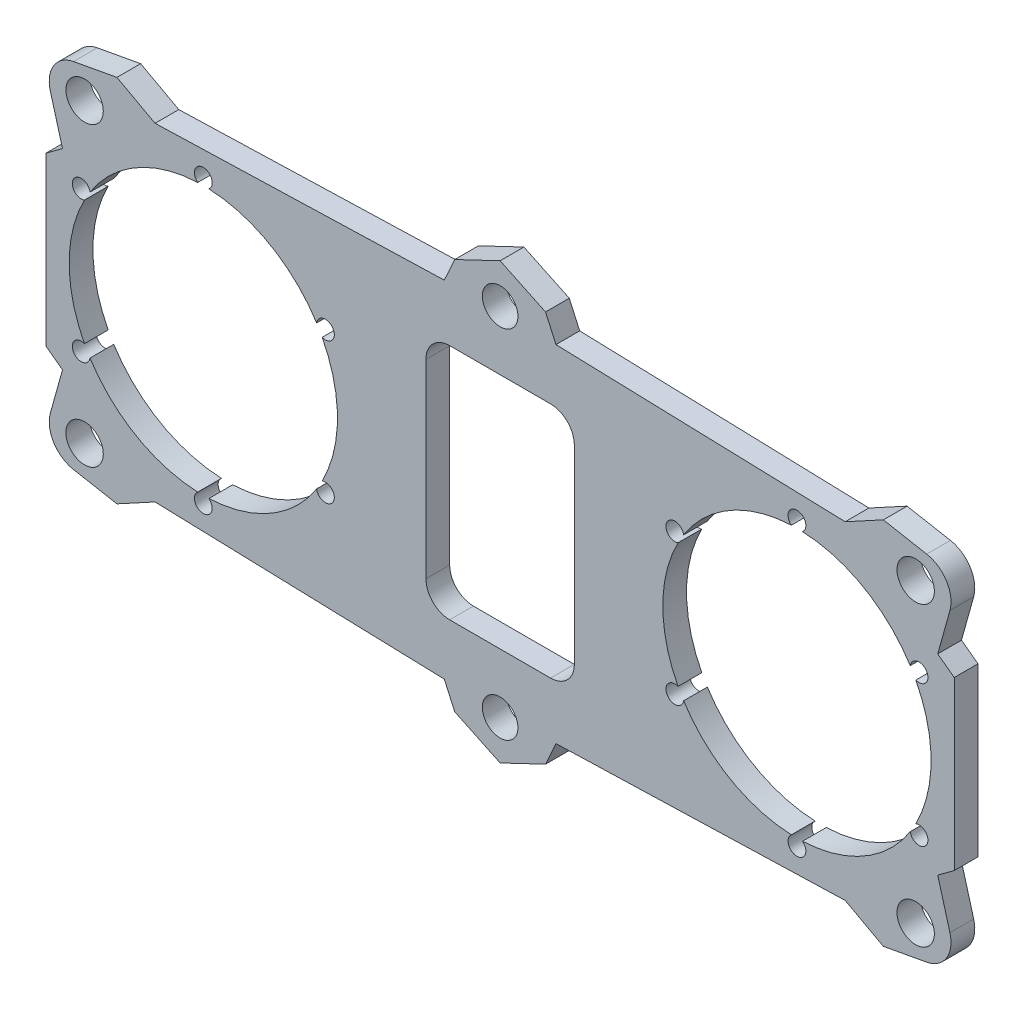
from build123d import *

# Parameters (mm, degrees)
SKETCH1_R           = 3
SKETCH1_R_2         = 22.6
BOSS_EXTRUDE1_DEPTH = 4
CUT_EXTRUDE1_DEPTH  = 5
SKETCH3_R           = 3.15
BOSS_EXTRUDE2_DEPTH = 4
FILLET1_R           = 5
SKETCH4_R           = 1.5
CUT_EXTRUDE2_DEPTH  = 5


with BuildPart() as part:
    # Sketch1 → Boss-Extrude1 (new body)
    with BuildSketch(Plane.XY):
        Polygon((0, 36.632796194), (-7.647271147, 32.990762303), (-9.405300929, 29.104152359), (-58.126981429, 27.62278105), (-76.5, 14.085859857), (-76.5, -14.085859857), (-58.126981429, -27.62278105), (-9.405300929, -29.104152359), (-7.647271147, -32.990762303), (0, -36.632796194), (7.647271147, -32.990762303), (9.405300929, -29.104152359), (58.126981429, -27.62278105), (76.5, -14.085859857), (76.5, 14.085859857), (58.126981429, 27.62278105), (9.405300929, 29.104152359), (7.647271147, 32.990762303), align=None)
        with Locations((0, 30)):
            Circle(SKETCH1_R, mode=Mode.SUBTRACT)
        with Locations((-50, 0)):
            Circle(SKETCH1_R_2, mode=Mode.SUBTRACT)
        with Locations((50, 0)):
            Circle(SKETCH1_R_2, mode=Mode.SUBTRACT)
        with Locations((0, -30)):
            Circle(SKETCH1_R, mode=Mode.SUBTRACT)
    extrude(amount=BOSS_EXTRUDE1_DEPTH)

    # Sketch2 → Cut-Extrude1 (cut, through all)
    with BuildSketch(Plane.XY.offset(4)):
        with BuildLine():
            Line((8.5, 20), (-8.5, 20))
            ThreePointArc((-8.5, 20), (-11.328427125, 18.828427125), (-12.5, 16))
            Line((-12.5, 16), (-12.5, -16))
            ThreePointArc((-12.5, -16), (-11.328427125, -18.828427125), (-8.5, -20))
            Line((-8.5, -20), (8.5, -20))
            ThreePointArc((8.5, -20), (11.328427125, -18.828427125), (12.5, -16))
            Line((12.5, -16), (12.5, 16))
            ThreePointArc((12.5, 16), (11.328427125, 18.828427125), (8.5, 20))
        make_face()
    extrude(amount=-CUT_EXTRUDE1_DEPTH, mode=Mode.SUBTRACT)

    # Sketch3 → Boss-Extrude2 (add)
    with BuildSketch(Plane.XY.offset(4)):
        Polygon((-58.126981429, 27.62278105), (-64.551915182, 31.10998542), (-77.245081729, 28.773819798), (-73.717039059, 16.136297176), align=None)
        with Locations((-70, 25)):
            Circle(SKETCH3_R, mode=Mode.SUBTRACT)
        Polygon((73.717039059, 16.136297176), (58.126981429, 27.62278105), (64.551915182, 31.10998542), (77.245081729, 28.773819798), align=None)
        with Locations((70, 25)):
            Circle(SKETCH3_R, mode=Mode.SUBTRACT)
        Polygon((58.126981429, -27.62278105), (64.551915182, -31.10998542), (77.245081729, -28.773819798), (73.717039059, -16.136297176), align=None)
        with Locations((70, -25)):
            Circle(SKETCH3_R, mode=Mode.SUBTRACT)
        Polygon((-73.717039059, -16.136297176), (-58.126981429, -27.62278105), (-64.551915182, -31.10998542), (-77.245081729, -28.773819798), align=None)
        with Locations((-70, -25)):
            Circle(SKETCH3_R, mode=Mode.SUBTRACT)
    extrude(amount=-BOSS_EXTRUDE2_DEPTH)

    # Fillet1
    fillet1_edges = [part.edges().sort_by_distance(p)[0] for p in [
        (77.245081729, 28.773819798, 2),
        (77.245081729, -28.773819798, 2),
        (-77.245081729, -28.773819798, 2),
        (-77.245081729, 28.773819798, 2),
    ]]
    fillet(fillet1_edges, radius=FILLET1_R)

    # Sketch4 → Cut-Extrude2 (cut, through all)
    with BuildSketch(Plane.XY.offset(4)):
        with Locations((-50, 23.75)):
            Circle(SKETCH4_R)
        with Locations((-70.56810334, 11.875)):
            Circle(SKETCH4_R)
        with Locations((-70.56810334, -11.875)):
            Circle(SKETCH4_R)
        with Locations((-50, -23.75)):
            Circle(SKETCH4_R)
        with Locations((-29.43189666, -11.875)):
            Circle(SKETCH4_R)
        with Locations((-29.43189666, 11.875)):
            Circle(SKETCH4_R)
        with Locations((29.43189666, 11.875)):
            Circle(SKETCH4_R)
        with Locations((29.43189666, -11.875)):
            Circle(SKETCH4_R)
        with Locations((50, -23.75)):
            Circle(SKETCH4_R)
        with Locations((70.56810334, -11.875)):
            Circle(SKETCH4_R)
        with Locations((70.56810334, 11.875)):
            Circle(SKETCH4_R)
        with Locations((50, 23.75)):
            Circle(SKETCH4_R)
    extrude(amount=-CUT_EXTRUDE2_DEPTH, mode=Mode.SUBTRACT)


solid = part.part
